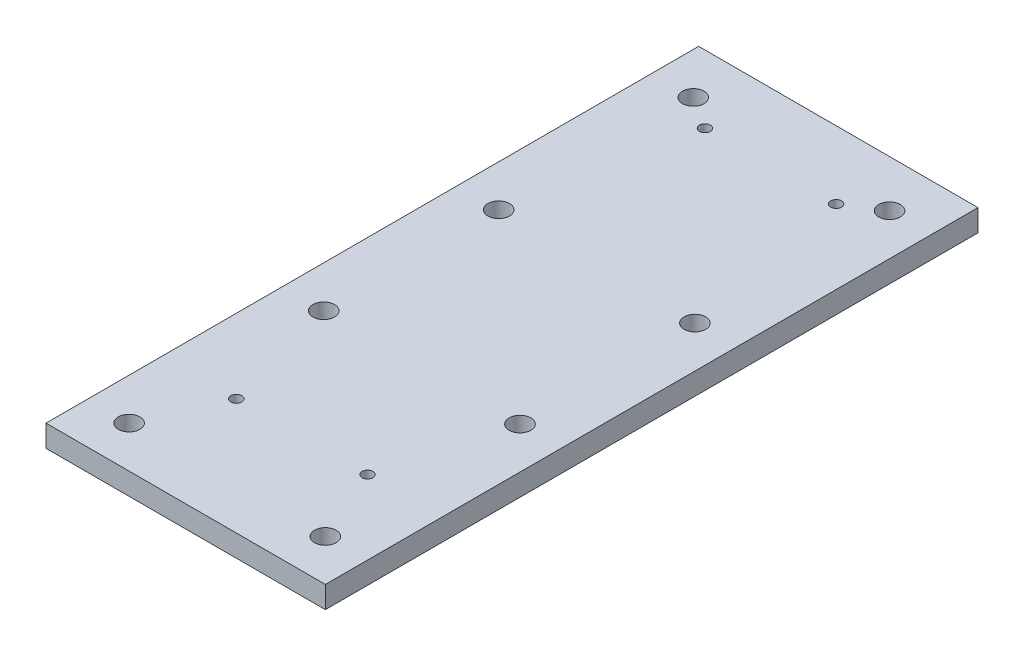
from build123d import *

# Parameters (mm, degrees)
SKETCH1_W           = 127.75
SKETCH1_H           = 298.45
SKETCH1_R           = 4.95
BOSS_EXTRUDE1_DEPTH = 10
SKETCH4_R           = 2.5
CUT_EXTRUDE2_DEPTH  = 11


with BuildPart() as part:
    # Sketch1 → Boss-Extrude1 (new body)
    with BuildSketch(Plane(origin=(0, 0, 0), x_dir=(1, 0, 0), z_dir=(0, 1, 0))):
        with Locations((63.875, 149.225)):
            Rectangle(SKETCH1_W, SKETCH1_H)
        with Locations((19, 277)):
            Circle(SKETCH1_R, mode=Mode.SUBTRACT)
        with Locations((108.75, 277)):
            Circle(SKETCH1_R, mode=Mode.SUBTRACT)
        with Locations((108.75, 19)):
            Circle(SKETCH1_R, mode=Mode.SUBTRACT)
        with Locations((19, 19)):
            Circle(SKETCH1_R, mode=Mode.SUBTRACT)
        with Locations((19, 108)):
            Circle(SKETCH1_R, mode=Mode.SUBTRACT)
        with Locations((108.75, 108)):
            Circle(SKETCH1_R, mode=Mode.SUBTRACT)
        with Locations((19, 188)):
            Circle(SKETCH1_R, mode=Mode.SUBTRACT)
        with Locations((108.75, 188)):
            Circle(SKETCH1_R, mode=Mode.SUBTRACT)
    extrude(amount=BOSS_EXTRUDE1_DEPTH)

    # Sketch4 → Cut-Extrude2 (cut, through all)
    with BuildSketch(Plane(origin=(0, 10, 0), x_dir=(1, 0, 0), z_dir=(0, 1, 0))):
        with Locations((93.875, 267.45)):
            Circle(SKETCH4_R)
        with Locations((33.875, 267.45)):
            Circle(SKETCH4_R)
        with Locations((93.875, 53.1375)):
            Circle(SKETCH4_R)
        with Locations((33.875, 53.1375)):
            Circle(SKETCH4_R)
    extrude(amount=-CUT_EXTRUDE2_DEPTH, mode=Mode.SUBTRACT)


solid = part.part
